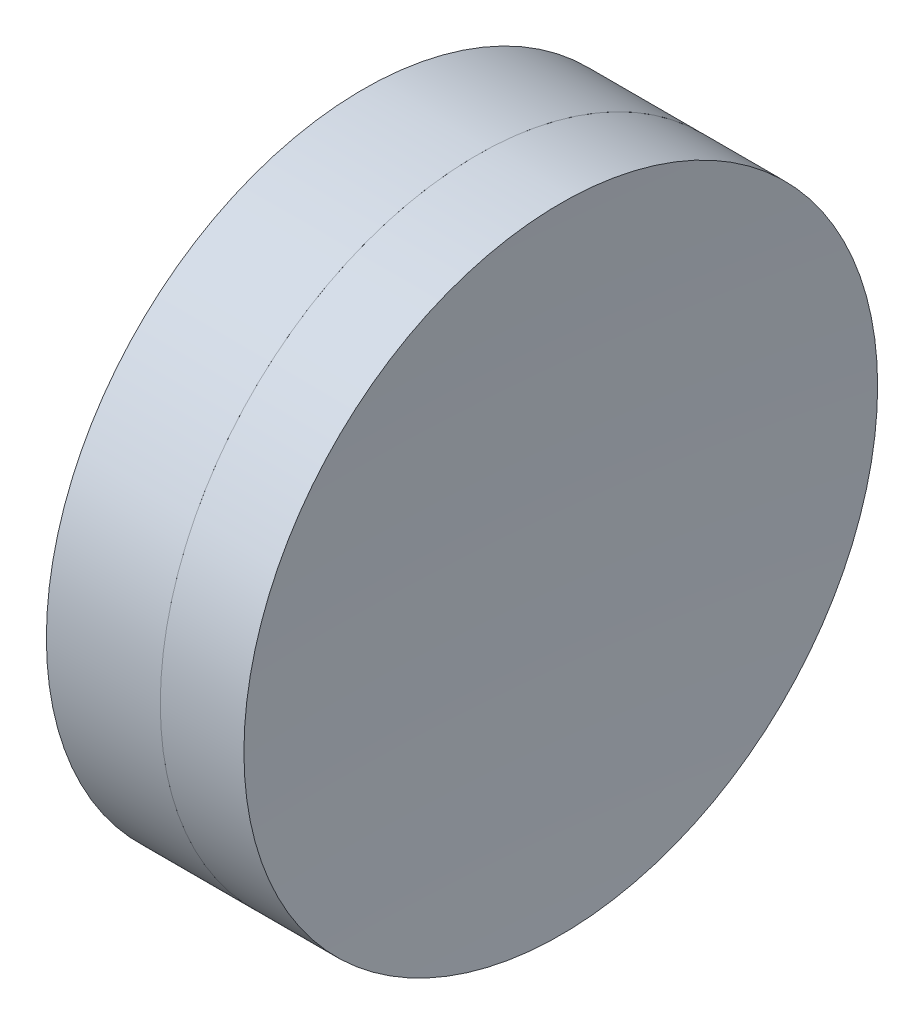
from build123d import *


with BuildPart() as part:
    # 草图1 one side → 旋转1 (revolve)
    with BuildSketch(Plane(origin=(0, 0, 0), x_dir=(1, 0, 0), z_dir=(0, 1, 0)), mode=Mode.PRIVATE) as revolve_1_sk:
        with BuildLine():
            Line((221.68201954, 12.5), (217.187794646, 12.5))
            ThreePointArc((217.187794646, 12.5), (217.825305555, 6.264444928), (218.038136363, 0))
            Line((218.038136363, 0), (220.538136363, 0))
            ThreePointArc((220.538136363, 0), (220.824703358, 6.276114816), (221.68201954, 12.5))
        make_face()
    revolve(revolve_1_sk.sketch.rotate(Axis((-0.816062176, 0, 0), (1, 0, 0)), 180), axis=Axis((-0.816062176, 0, 0), (1, 0, 0)))  # turned: the seam where the file's is


with BuildPart() as body_2:
    # 草图2 one side → 旋转3 (revolve)
    with BuildSketch(Plane(origin=(0, 0, 0), x_dir=(1, 0, 0), z_dir=(0, 1, 0)), mode=Mode.PRIVATE) as revolve_3_sk:
        with BuildLine():
            Line((224.981180014, 12.5), (221.68201954, 12.5))
            ThreePointArc((221.68201954, 12.5), (220.824703358, 6.276114816), (220.538136363, 0))
            Line((220.538136363, 0), (224.598136363, 0))
            ThreePointArc((224.598136363, 0), (224.693919746, 6.25293376), (224.981180014, 12.5))
        make_face()
    revolve(revolve_3_sk.sketch.rotate(Axis((217.187794646, 0, 0), (1, 0, 0)), 180), axis=Axis((217.187794646, 0, 0), (1, 0, 0)))  # turned: the seam where the file's is


solid = Compound([part.part, body_2.part])
